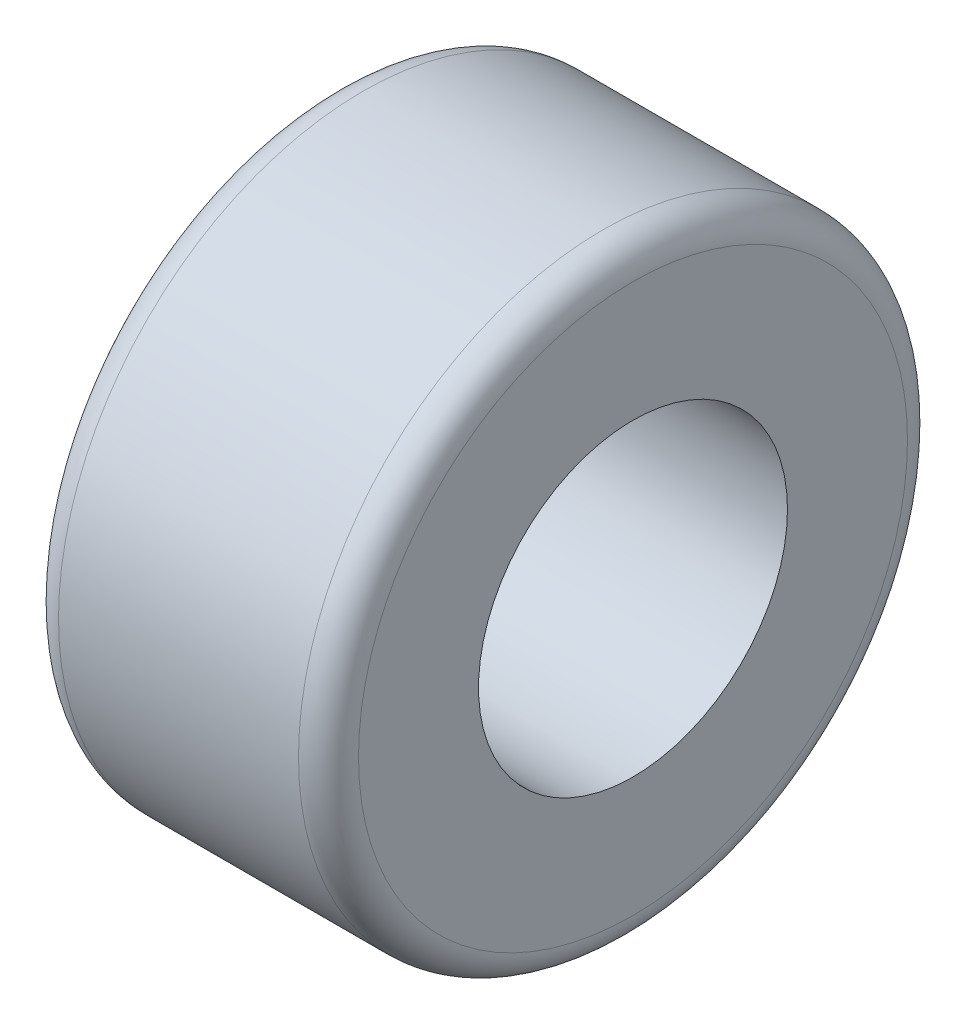
from build123d import *

# Parameters (mm, degrees)
SKETCH1_R           = 10.15
SKETCH1_R_2         = 5.15
BOSS_EXTRUDE1_DEPTH = 10
FILLET1_R           = 1


with BuildPart() as part:
    # Sketch1 → Boss-Extrude1 (new body)
    with BuildSketch(Plane(origin=(0, 0, 0), x_dir=(0, 0, -1), z_dir=(1, 0, 0))):
        Circle(SKETCH1_R)
        Circle(SKETCH1_R_2, mode=Mode.SUBTRACT)
    extrude(amount=BOSS_EXTRUDE1_DEPTH)

    # Fillet1
    fillet1_edges = [part.edges().sort_by_distance(p)[0] for p in [
        (0, 0, 10.15),
        (10, 0, 10.15),
    ]]
    fillet(fillet1_edges, radius=FILLET1_R)


solid = part.part
